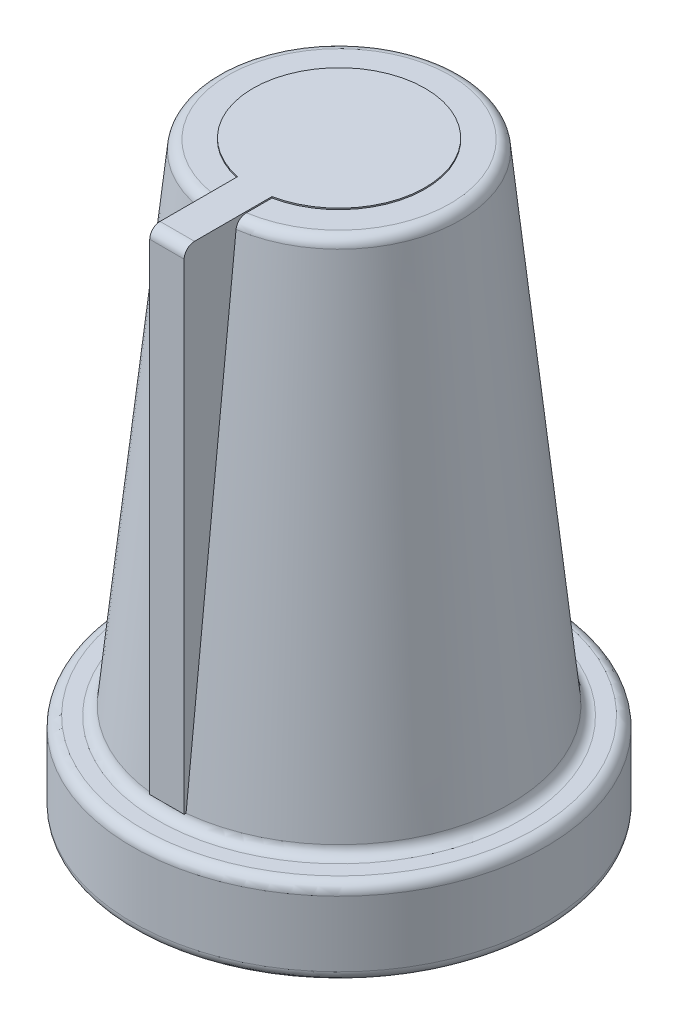
from build123d import *

# Parameters (mm, degrees)
CROQUIS2_W              = 1
CROQUIS2_H              = 14.230822787
SALIENTE_EXTRUIR1_DEPTH = 5
SALIENTE_EXTRUIR3_DEPTH = 0.6
CORTAR_EXTRUIR1_DEPTH   = 10.6
CROQUIS5_R              = 3
CORTAR_EXTRUIR2_DEPTH   = 13.937547


with BuildPart() as part:
    # Croquis1 → Revolución1 (revolve)
    with BuildSketch(Plane.XY):
        with BuildLine():
            ThreePointArc((0.729390716, 10), (0.930329965, 9.922763143), (1.027803108, 9.730822787))
            Line((1.027803108, 9.730822787), (2.469890767, -4.230822787))
            ThreePointArc((2.469890767, -4.230822787), (2.56736391, -4.422763143), (2.768303159, -4.5))
            Line((2.768303159, -4.5), (3.2, -4.5))
            ThreePointArc((3.2, -4.5), (3.412132034, -4.587867966), (3.5, -4.8))
            Line((3.5, -4.8), (3.5, -6.7))
            ThreePointArc((3.5, -6.7), (3.412132034, -6.912132034), (3.2, -7))
            Line((3.2, -7), (3, -7))
            Line((3, -7), (3, -5.3))
            ThreePointArc((3, -5.3), (2.912132034, -5.087867966), (2.7, -5))
            Line((2.7, -5), (0.5, -5))
            Line((0.5, -5), (0.5, 8.637546769))
            ThreePointArc((0.5, 8.637546769), (0.412132034, 8.849678803), (0.2, 8.937546769))
            Line((0.2, 8.937546769), (-2.5, 8.937546769))
            Line((-2.5, 8.937546769), (-2.5, 9.437546769))
            Line((-2.5, 9.437546769), (0, 9.437546769))
            Line((0, 9.437546769), (0, 10))
            Line((0, 10), (0.729390716, 10))
        make_face()
    revolve(axis=Axis((-2.5, -7, 0), (0, 1, 0)))

    # Croquis2 → Saliente-Extruir1 (add)
    with BuildSketch(Plane.XY):
        with Locations((-2.5, 2.884588606)):
            Rectangle(CROQUIS2_W, CROQUIS2_H)
    extrude(amount=SALIENTE_EXTRUIR1_DEPTH)

    # Croquis3 → Saliente-Extruir3 (add)
    with BuildSketch(Plane(origin=(0, 9.437546769, 0), x_dir=(1, 0, 0), z_dir=(0, 1, 0))):
        with BuildLine():
            Line((-3, -4.944675342), (-2, -5))
            Line((-2, -5), (-2, -2.449489743))
            ThreePointArc((-2, -2.449489743), (-2.5, 2.5), (-3, -2.449489743))
            Line((-3, -2.449489743), (-3, -4.944675342))
        make_face()
    extrude(amount=SALIENTE_EXTRUIR3_DEPTH)

    # Croquis4 → Cortar-Extruir1 (cut)
    with BuildSketch(Plane(origin=(-2, 0, 0), x_dir=(0, 0, -1), z_dir=(1, 0, 0))):
        with BuildLine():
            Line((-5, 9.737546769), (-5, 10.037546769))
            Line((-5, 10.037546769), (-4.7, 10.037546769))
            ThreePointArc((-4.7, 10.037546769), (-4.912132034, 9.949678803), (-5, 9.737546769))
        make_face()
    extrude(amount=-CORTAR_EXTRUIR1_DEPTH, mode=Mode.SUBTRACT)

    # Croquis5 → Cortar-Extruir2 (cut)
    with BuildSketch(Plane.XZ.offset(5)):
        with Locations((-2.5, 0)):
            Circle(CROQUIS5_R)
    extrude(amount=-CORTAR_EXTRUIR2_DEPTH, mode=Mode.SUBTRACT)


solid = part.part
